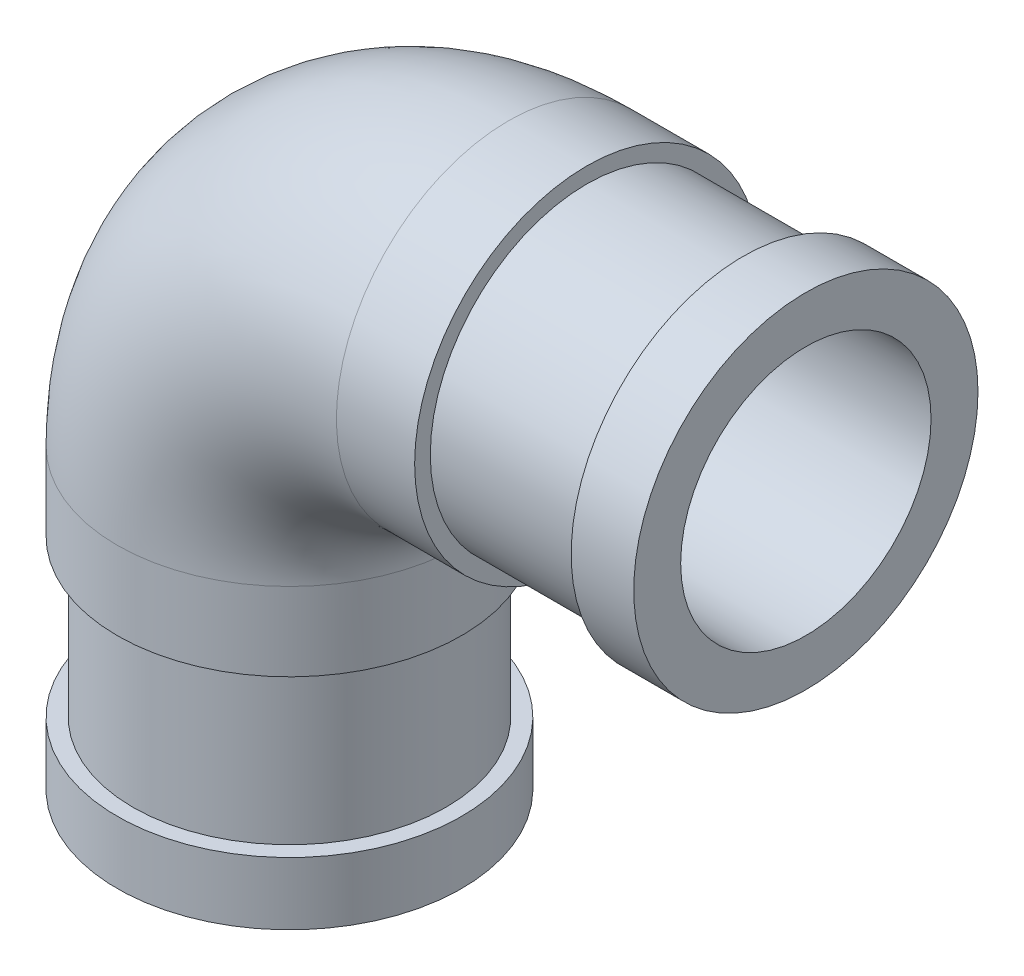
from build123d import *

# Parameters (mm, degrees)
SWEEP_THIN1_PROFILE_R   = 11
SWEEP_THIN1_PROFILE_R_2 = 8
SKETCH70_R              = 10
SKETCH70_R_2            = 8
BOSS_EXTRUDE1_DEPTH     = 10
SKETCH71_R              = 11
SKETCH71_R_2            = 8
BOSS_EXTRUDE2_DEPTH     = 4
SKETCH72_R              = 10
SKETCH72_R_2            = 8
BOSS_EXTRUDE3_DEPTH     = 10
SKETCH73_R              = 11
SKETCH73_R_2            = 8
BOSS_EXTRUDE4_DEPTH     = 4


with BuildPart() as part:
    # Sweep-Thin1: sweep along a path in Sketch1
    with BuildLine(Plane.XY) as sweep_thin1_path:
        Line((-14, -5), (-14, 0))
        ThreePointArc((-14, 0), (-9.899495, 9.899495), (0, 14))
        Line((0, 14), (5, 14))
    # Sweep-Thin1 profile (on start of the path) → Sweep-Thin1 (sweep)
    with BuildSketch(Plane(origin=(-14, -5, 0), x_dir=(0, 0, 1), z_dir=(0, 1, 0))):
        Circle(SWEEP_THIN1_PROFILE_R)
        Circle(SWEEP_THIN1_PROFILE_R_2, mode=Mode.SUBTRACT)
    sweep(path=sweep_thin1_path.line)

    # Sketch70 → Boss-Extrude1 (add)
    with BuildSketch(Plane.XZ.offset(5)):
        with Locations(Location((-14, 0, 0), (0, 0, 270))):
            Circle(SKETCH70_R)
        with Locations(Location((-14, 0, 0), (0, 0, 180))):
            Circle(SKETCH70_R_2, mode=Mode.SUBTRACT)
    extrude(amount=BOSS_EXTRUDE1_DEPTH)

    # Sketch71 → Boss-Extrude2 (add)
    with BuildSketch(Plane.XZ.offset(15)):
        with Locations(Location((-14, 0, 0), (0, 0, 90))):
            Circle(SKETCH71_R)
        with Locations(Location((-14, 0, 0), (0, 0, 180))):
            Circle(SKETCH71_R_2, mode=Mode.SUBTRACT)
    extrude(amount=BOSS_EXTRUDE2_DEPTH)

    # Sketch72 → Boss-Extrude3 (add)
    with BuildSketch(Plane(origin=(5, 0, 0), x_dir=(0, 0, -1), z_dir=(1, 0, 0))):
        with Locations((0, 14)):
            Circle(SKETCH72_R)
        with Locations((0, 14)):
            Circle(SKETCH72_R_2, mode=Mode.SUBTRACT)
    extrude(amount=BOSS_EXTRUDE3_DEPTH)

    # Sketch73 → Boss-Extrude4 (add)
    with BuildSketch(Plane(origin=(15, 0, 0), x_dir=(0, 0, -1), z_dir=(1, 0, 0))):
        with Locations(Location((0, 14, 0), (0, 0, 90))):
            Circle(SKETCH73_R)
        with Locations((0, 14)):
            Circle(SKETCH73_R_2, mode=Mode.SUBTRACT)
    extrude(amount=BOSS_EXTRUDE4_DEPTH)


solid = part.part
